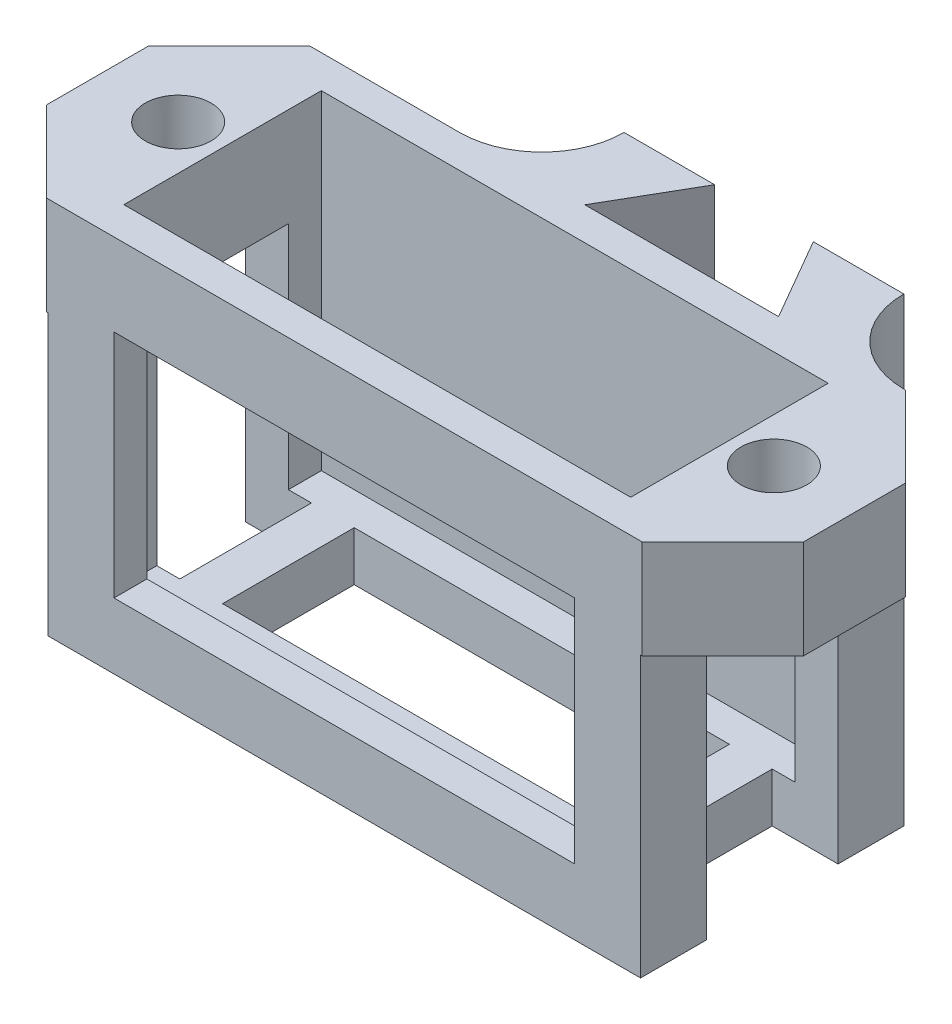
from build123d import *

# Parameters (mm, degrees)
SKETCH1_W      = 30
SKETCH1_H      = 15
SKETCH1_H_2    = 5
EXTRUDE1_DEPTH = 8
EXTRUDE2_START = 5
SKETCH2_R      = 2
SKETCH2_W      = 30.8
SKETCH2_H      = 12
SKETCH2_W_2    = 22.8
SKETCH2_H_2    = 8
EXTRUDE2_DEPTH = 20
EXTRUDE3_START = 6
SKETCH3_W      = 28
SKETCH3_H      = 14
EXTRUDE3_DEPTH = 2
SKETCH3_3_W    = 4
SKETCH3_3_H    = 17
EXTRUDE4_DEPTH = 4
EXTRUDE5_START = -15
SKETCH2_3_W    = 22.8
SKETCH2_3_H    = 8
EXTRUDE5_DEPTH = 3
EXTRUDE6_START = -18
EXTRUDE6_DEPTH = 23


with BuildPart() as part:
    # Sketch1 → Extrude1 (new, symmetric)
    with BuildSketch(Plane.XY):
        Polygon((-15, 0), (-15, 5), (-23, 5), (-23, -1), (-18, -1), (-18, -18), (18, -18), (18, -1), (23, -1), (23, 5), (15, 5), (15, 0), (15, -15), (-15, -15), align=None)
        with Locations((0, -7.5)):
            Rectangle(SKETCH1_W, SKETCH1_H)
        with Locations((0, 2.5)):
            Rectangle(SKETCH1_W, SKETCH1_H_2)
    extrude(amount=EXTRUDE1_DEPTH, both=True)

    # Sketch2 → Extrude2 (cut)
    with BuildSketch(Plane(origin=(0, 0, 0), x_dir=(1, 0, 0), z_dir=(0, 1, 0)).offset(EXTRUDE2_START)):
        Polygon((-23, -8), (-23, -3.1), (-18.1, -8), align=None)
        with Locations(Location((-18.1, 0, 0), (0, 0, 272.865983983))):
            Circle(SKETCH2_R)
        Polygon((-23, 8), (-18.1, 8), (-23, 3.1), align=None)
        Rectangle(SKETCH2_W, SKETCH2_H)
        Rectangle(SKETCH2_W_2, SKETCH2_H_2, mode=Mode.SUBTRACT)
        Rectangle(SKETCH2_W_2, SKETCH2_H_2)
        Polygon((23, 3.1), (23, 8), (18.1, 8), align=None)
        with Locations(Location((18.1, 0, 0), (0, 0, 267.134016017))):
            Circle(SKETCH2_R)
        Polygon((18.1, -8), (23, -8), (23, -3.1), align=None)
    extrude(amount=-EXTRUDE2_DEPTH, mode=Mode.SUBTRACT)

    # Sketch3 (on Front Plane) → Extrude3 (cut)
    with BuildSketch(Plane.XY.offset(EXTRUDE3_START)):
        with Locations((0, -7)):
            Rectangle(SKETCH3_W, SKETCH3_H)
    extrude(amount=EXTRUDE3_DEPTH, mode=Mode.SUBTRACT)

    # Sketch3_3 → Extrude4 (cut, symmetric)
    with BuildSketch(Plane.XY):
        with Locations((-16, -9.5)):
            Rectangle(SKETCH3_3_W, SKETCH3_3_H)
        with Locations((16, -9.5)):
            Rectangle(SKETCH3_3_W, SKETCH3_3_H)
    extrude(amount=EXTRUDE4_DEPTH, both=True, mode=Mode.SUBTRACT)

    # Sketch2_3 → Extrude5 (cut)
    with BuildSketch(Plane(origin=(0, 0, 0), x_dir=(1, 0, 0), z_dir=(0, 1, 0)).offset(EXTRUDE5_START)):
        Rectangle(SKETCH2_3_W, SKETCH2_3_H)
    extrude(amount=-EXTRUDE5_DEPTH, mode=Mode.SUBTRACT)

    # Sketch4 → Extrude6 (add)
    with BuildSketch(Plane(origin=(0, 0, 0), x_dir=(1, 0, 0), z_dir=(0, 1, 0)).offset(EXTRUDE6_START)):
        with BuildLine():
            Line((10.386751346, 8), (18, 8))
            ThreePointArc((18, 8), (14.464466094, 9.464466094), (13, 13))
            Line((13, 13), (7.5, 13))
            Line((7.5, 13), (10.386751346, 8))
        make_face()
        with BuildLine():
            Line((-9, 8), (-1.386751346, 8))
            Line((-1.386751346, 8), (1.5, 13))
            Line((1.5, 13), (-4, 13))
            ThreePointArc((-4, 13), (-5.464466094, 9.464466094), (-9, 8))
        make_face()
    extrude(amount=EXTRUDE6_DEPTH)


solid = part.part
